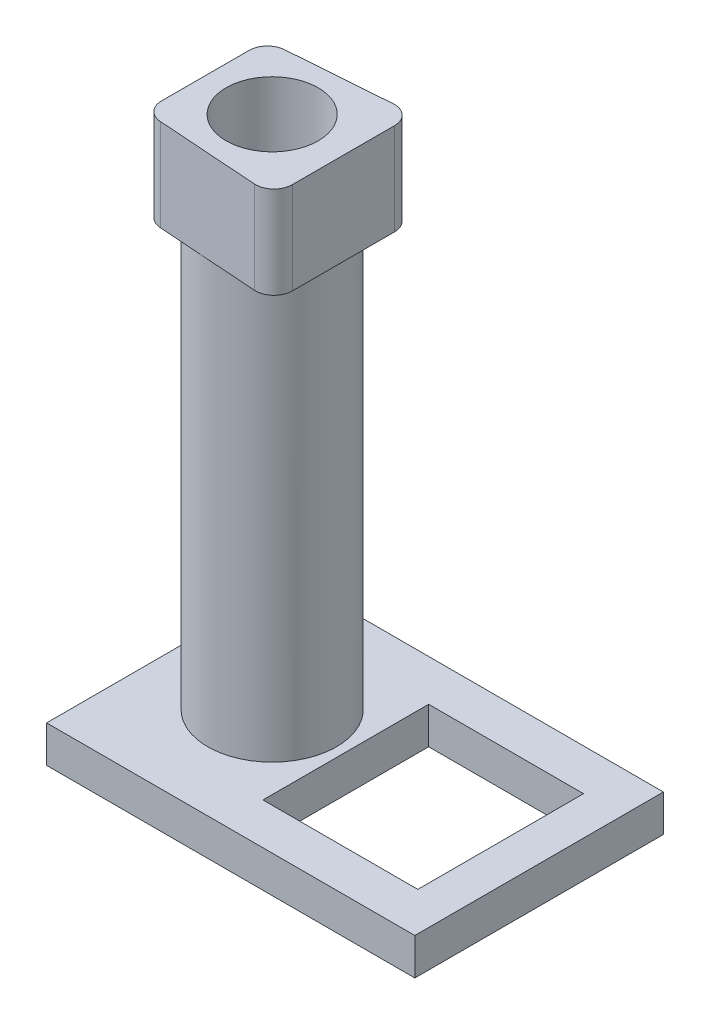
from build123d import *

# Parameters (mm, degrees)
SKETCH_1_W        = 200
SKETCH_1_H        = 135
SKETCH_1_W_2      = 84.112104212
SKETCH_1_H_2      = 90
EXTRUDE_1_DEPTH   = 20
SKETCH_3_R        = 35
SKETCH_3_R_2      = 25
EXTRUDE_1_2_DEPTH = 230
SKETCH_4_R        = 25
EXTRUDE_2_DEPTH   = 50


with BuildPart() as part:
    # Эскиз1 → Extrude 1 (new body)
    with BuildSketch(Plane(origin=(0, 0, 0), x_dir=(1, 0, 0), z_dir=(0, 1, 0))):
        with Locations((45, 0)):
            Rectangle(SKETCH_1_W, SKETCH_1_H)
        with Locations((82.056052106, 0)):
            Rectangle(SKETCH_1_W_2, SKETCH_1_H_2, mode=Mode.SUBTRACT)
    extrude(amount=EXTRUDE_1_DEPTH)

    # Эскиз3 → Extrude 1 2 (add)
    with BuildSketch(Plane(origin=(0, 20, 0), x_dir=(1, 0, 0), z_dir=(0, 1, 0))):
        Circle(SKETCH_3_R)
        Circle(SKETCH_3_R_2, mode=Mode.SUBTRACT)
    extrude(amount=EXTRUDE_1_2_DEPTH)

    # Эскиз4 → Бобышка-Вытянуть2 (add)
    with BuildSketch(Plane(origin=(0, 250, 0), x_dir=(1, 0, 0), z_dir=(0, 1, 0))):
        with BuildLine():
            Line((38.567048096, 27.880540306), (38.567048096, -27.601676263))
            ThreePointArc((38.567048096, -27.601676263), (35.38747425, -34.914800567), (27.87069068, -37.577401116))
            Line((27.87069068, -37.577401116), (-27.024888661, -33.745404507))
            ThreePointArc((-27.024888661, -33.745404507), (-33.641655548, -30.590105807), (-36.328531244, -23.769679653))
            Line((-36.328531244, -23.769679653), (-36.328531244, 23.781195095))
            ThreePointArc((-36.328531244, 23.781195095), (-33.658156001, 30.583885807), (-27.07321106, 33.753429146))
            Line((-27.07321106, 33.753429146), (27.822368281, 37.852774357))
            ThreePointArc((27.822368281, 37.852774357), (35.369738808, 35.210165063), (38.567048096, 27.880540306))
        make_face()
        Circle(SKETCH_4_R, mode=Mode.SUBTRACT)
    extrude(amount=EXTRUDE_2_DEPTH)


solid = part.part
